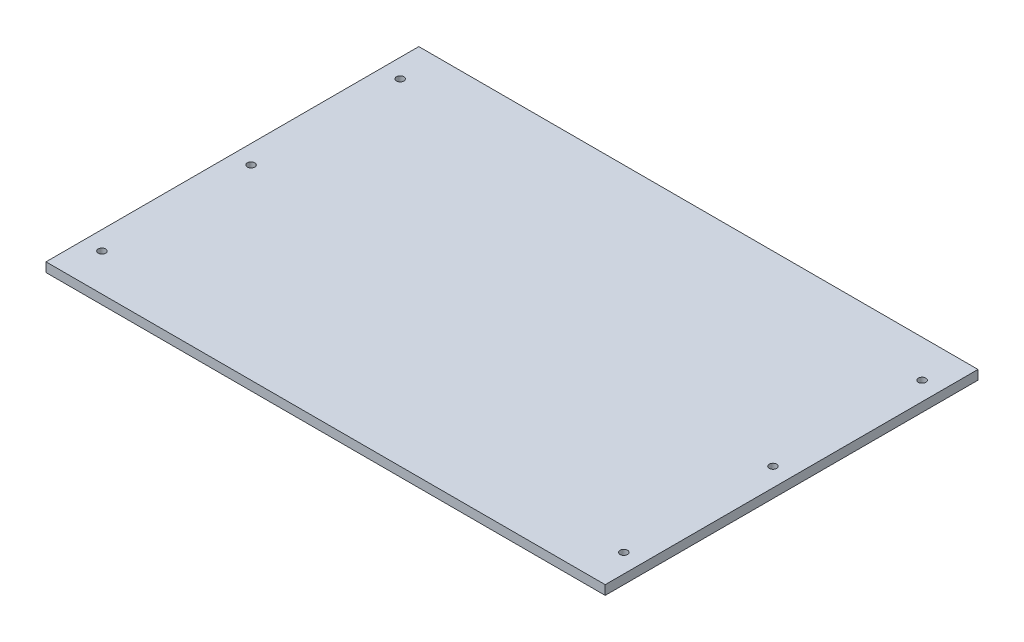
from build123d import *

# Parameters (mm, degrees)
SKETCH1_W           = 300
SKETCH1_H           = 200
SKETCH1_R           = 2
BOSS_EXTRUDE1_DEPTH = 5


with BuildPart() as part:
    # Sketch1 → Boss-Extrude1 (new body)
    with BuildSketch(Plane(origin=(0, 0, 0), x_dir=(1, 0, 0), z_dir=(0, 1, 0))):
        Rectangle(SKETCH1_W, SKETCH1_H)
        with Locations((-140, 80)):
            Circle(SKETCH1_R, mode=Mode.SUBTRACT)
        with Locations((-140, -80)):
            Circle(SKETCH1_R, mode=Mode.SUBTRACT)
        with Locations((-140, 0)):
            Circle(SKETCH1_R, mode=Mode.SUBTRACT)
        with Locations((140, -80)):
            Circle(SKETCH1_R, mode=Mode.SUBTRACT)
        with Locations((140, 0)):
            Circle(SKETCH1_R, mode=Mode.SUBTRACT)
        with Locations((140, 80)):
            Circle(SKETCH1_R, mode=Mode.SUBTRACT)
    extrude(amount=BOSS_EXTRUDE1_DEPTH)


solid = part.part
